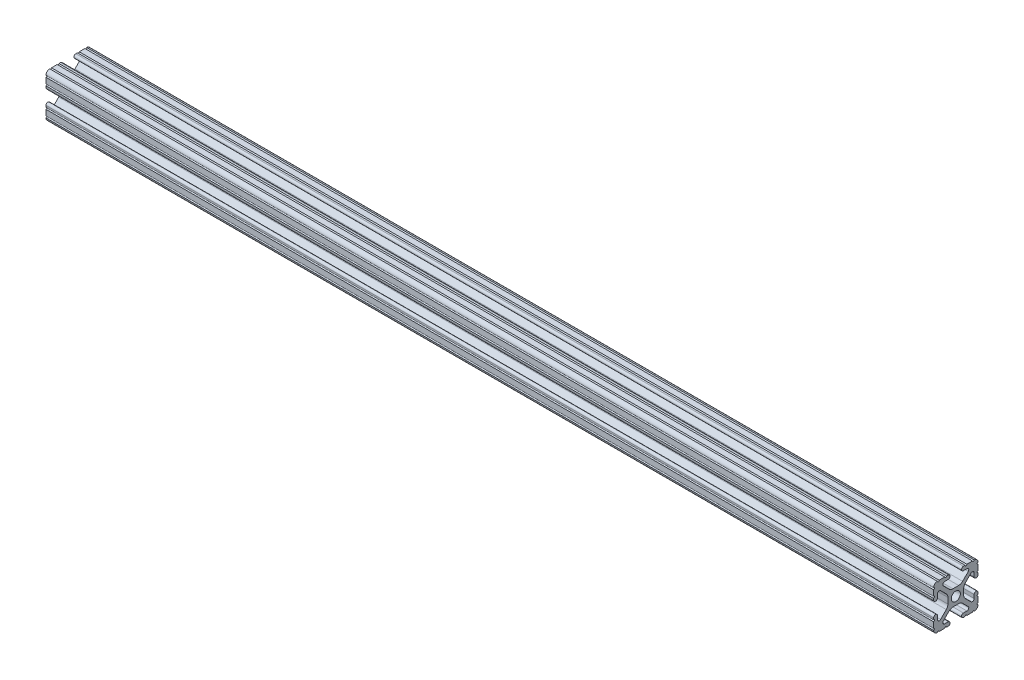
from build123d import *

# Parameters (mm, degrees)
SKETCH11_R              = 2.6035
FRACTIONAL_1010_1_DEPTH = 508


with BuildPart() as part:
    # Sketch11 → Fractional 1010(1) (new body)
    with BuildSketch(Plane.YZ.offset(-254)):
        with BuildLine():
            Line((10.5918, 12.7), (10.5664, 12.7))
            ThreePointArc((10.5664, 12.7), (10.0584, 12.192), (9.5504, 12.7))
            Line((9.5504, 12.7), (6.3246, 12.7))
            ThreePointArc((6.3246, 12.7), (5.8166, 12.192), (5.3086, 12.7))
            Line((5.3086, 12.7), (4.3561, 12.7))
            ThreePointArc((4.3561, 12.7), (3.2512, 11.5951), (4.3561, 10.4902))
            Line((4.3561, 10.4902), (6.370083786, 10.4902))
            ThreePointArc((6.370083786, 10.4902), (7.348856743, 9.836204819), (7.119204175, 8.681663397))
            Line((7.119204175, 8.681663397), (3.88464389, 5.447103113))
            ThreePointArc((3.88464389, 5.447103113), (2.854599758, 4.758849627), (1.63957986, 4.517167143))
            Line((1.63957986, 4.517167143), (-1.63957986, 4.517167143))
            ThreePointArc((-1.63957986, 4.517167143), (-2.854599758, 4.758849627), (-3.88464389, 5.447103113))
            Line((-3.88464389, 5.447103113), (-7.119204175, 8.681663397))
            ThreePointArc((-7.119204175, 8.681663397), (-7.348856743, 9.836204819), (-6.370083786, 10.4902))
            Line((-6.370083786, 10.4902), (-4.3561, 10.4902))
            ThreePointArc((-4.3561, 10.4902), (-3.2512, 11.5951), (-4.3561, 12.7))
            Line((-4.3561, 12.7), (-5.3086, 12.7))
            ThreePointArc((-5.3086, 12.7), (-5.8166, 12.192), (-6.3246, 12.7))
            Line((-6.3246, 12.7), (-9.5504, 12.7))
            ThreePointArc((-9.5504, 12.7), (-10.0584, 12.192), (-10.5664, 12.7))
            Line((-10.5664, 12.7), (-10.5918, 12.7))
            ThreePointArc((-10.5918, 12.7), (-12.082522516, 12.082522516), (-12.7, 10.5918))
            Line((-12.7, 10.5918), (-12.7, 10.5664))
            ThreePointArc((-12.7, 10.5664), (-12.192, 10.0584), (-12.7, 9.5504))
            Line((-12.7, 9.5504), (-12.7, 6.3246))
            ThreePointArc((-12.7, 6.3246), (-12.192, 5.8166), (-12.7, 5.3086))
            Line((-12.7, 5.3086), (-12.7, 4.3561))
            ThreePointArc((-12.7, 4.3561), (-11.5951, 3.2512), (-10.4902, 4.3561))
            Line((-10.4902, 4.3561), (-10.4902, 6.370083786))
            ThreePointArc((-10.4902, 6.370083786), (-9.836204819, 7.348856743), (-8.681663397, 7.119204175))
            Line((-8.681663397, 7.119204175), (-5.447103113, 3.88464389))
            ThreePointArc((-5.447103113, 3.88464389), (-4.758849627, 2.854599758), (-4.517167143, 1.63957986))
            Line((-4.517167143, 1.63957986), (-4.517167143, -1.63957986))
            ThreePointArc((-4.517167143, -1.63957986), (-4.758849627, -2.854599758), (-5.447103113, -3.88464389))
            Line((-5.447103113, -3.88464389), (-8.681663397, -7.119204175))
            ThreePointArc((-8.681663397, -7.119204175), (-9.836204819, -7.348856743), (-10.4902, -6.370083786))
            Line((-10.4902, -6.370083786), (-10.4902, -4.3561))
            ThreePointArc((-10.4902, -4.3561), (-11.5951, -3.2512), (-12.7, -4.3561))
            Line((-12.7, -4.3561), (-12.7, -5.3086))
            ThreePointArc((-12.7, -5.3086), (-12.192, -5.8166), (-12.7, -6.3246))
            Line((-12.7, -6.3246), (-12.7, -9.5504))
            ThreePointArc((-12.7, -9.5504), (-12.192, -10.0584), (-12.7, -10.5664))
            Line((-12.7, -10.5664), (-12.7, -10.5918))
            ThreePointArc((-12.7, -10.5918), (-12.082522516, -12.082522516), (-10.5918, -12.7))
            Line((-10.5918, -12.7), (-10.5664, -12.7))
            ThreePointArc((-10.5664, -12.7), (-10.0584, -12.192), (-9.5504, -12.7))
            Line((-9.5504, -12.7), (-6.3246, -12.7))
            ThreePointArc((-6.3246, -12.7), (-5.8166, -12.192), (-5.3086, -12.7))
            Line((-5.3086, -12.7), (-4.3561, -12.7))
            ThreePointArc((-4.3561, -12.7), (-3.2512, -11.5951), (-4.3561, -10.4902))
            Line((-4.3561, -10.4902), (-6.370083786, -10.4902))
            ThreePointArc((-6.370083786, -10.4902), (-7.348856743, -9.836204819), (-7.119204175, -8.681663397))
            Line((-7.119204175, -8.681663397), (-3.88464389, -5.447103113))
            ThreePointArc((-3.88464389, -5.447103113), (-2.854599758, -4.758849627), (-1.63957986, -4.517167143))
            Line((-1.63957986, -4.517167143), (1.63957986, -4.517167143))
            ThreePointArc((1.63957986, -4.517167143), (2.854599758, -4.758849627), (3.88464389, -5.447103113))
            Line((3.88464389, -5.447103113), (7.119204175, -8.681663397))
            ThreePointArc((7.119204175, -8.681663397), (7.348856743, -9.836204819), (6.370083786, -10.4902))
            Line((6.370083786, -10.4902), (4.3561, -10.4902))
            ThreePointArc((4.3561, -10.4902), (3.2512, -11.5951), (4.3561, -12.7))
            Line((4.3561, -12.7), (5.3086, -12.7))
            ThreePointArc((5.3086, -12.7), (5.8166, -12.192), (6.3246, -12.7))
            Line((6.3246, -12.7), (9.5504, -12.7))
            ThreePointArc((9.5504, -12.7), (10.0584, -12.192), (10.5664, -12.7))
            Line((10.5664, -12.7), (10.5918, -12.7))
            ThreePointArc((10.5918, -12.7), (12.082522516, -12.082522516), (12.7, -10.5918))
            Line((12.7, -10.5918), (12.7, -10.5664))
            ThreePointArc((12.7, -10.5664), (12.192, -10.0584), (12.7, -9.5504))
            Line((12.7, -9.5504), (12.7, -6.3246))
            ThreePointArc((12.7, -6.3246), (12.192, -5.8166), (12.7, -5.3086))
            Line((12.7, -5.3086), (12.7, -4.3561))
            ThreePointArc((12.7, -4.3561), (11.5951, -3.2512), (10.4902, -4.3561))
            Line((10.4902, -4.3561), (10.4902, -6.370083786))
            ThreePointArc((10.4902, -6.370083786), (9.836204819, -7.348856743), (8.681663397, -7.119204175))
            Line((8.681663397, -7.119204175), (5.447103113, -3.88464389))
            ThreePointArc((5.447103113, -3.88464389), (4.758849627, -2.854599758), (4.517167143, -1.63957986))
            Line((4.517167143, -1.63957986), (4.517167143, 1.63957986))
            ThreePointArc((4.517167143, 1.63957986), (4.758849627, 2.854599758), (5.447103113, 3.88464389))
            Line((5.447103113, 3.88464389), (8.681663397, 7.119204175))
            ThreePointArc((8.681663397, 7.119204175), (9.836204819, 7.348856743), (10.4902, 6.370083786))
            Line((10.4902, 6.370083786), (10.4902, 4.3561))
            ThreePointArc((10.4902, 4.3561), (11.5951, 3.2512), (12.7, 4.3561))
            Line((12.7, 4.3561), (12.7, 5.3086))
            ThreePointArc((12.7, 5.3086), (12.192, 5.8166), (12.7, 6.3246))
            Line((12.7, 6.3246), (12.7, 9.5504))
            ThreePointArc((12.7, 9.5504), (12.192, 10.0584), (12.7, 10.5664))
            Line((12.7, 10.5664), (12.7, 10.5918))
            ThreePointArc((12.7, 10.5918), (12.082522516, 12.082522516), (10.5918, 12.7))
        make_face()
        Circle(SKETCH11_R, mode=Mode.SUBTRACT)
    extrude(amount=FRACTIONAL_1010_1_DEPTH)


solid = part.part
